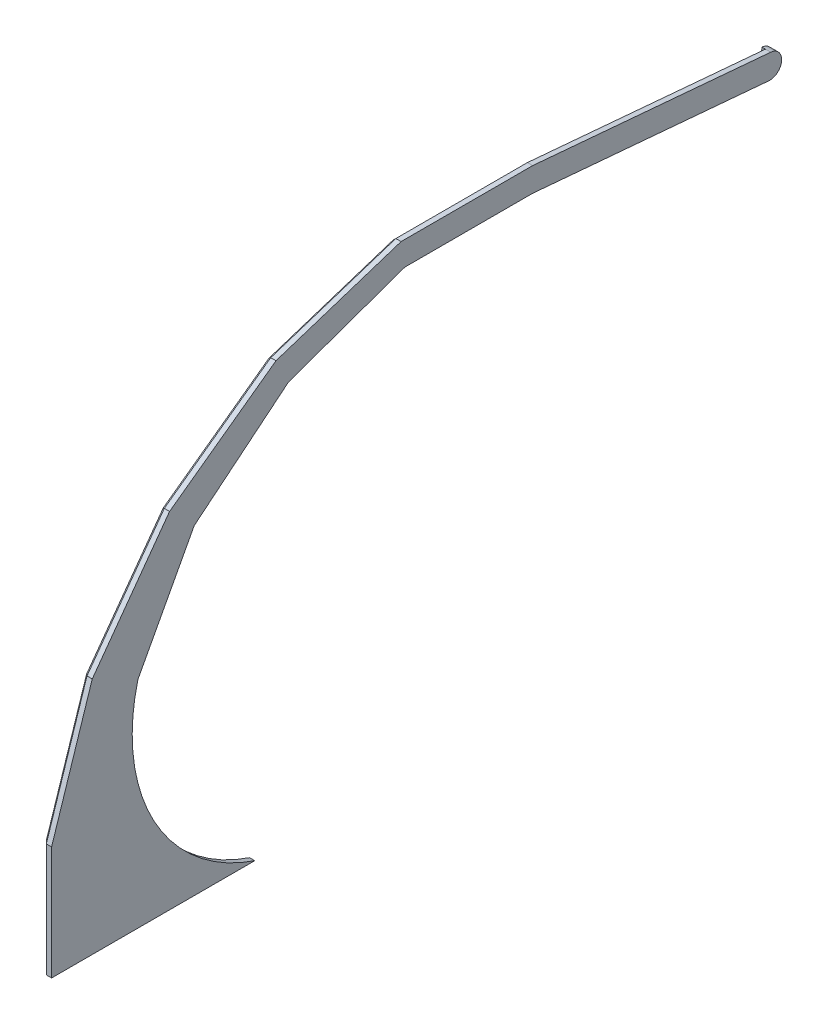
from build123d import *

# Parameters (mm, degrees)
BOSS_EXTRUDE1_DEPTH = 4.4
SKETCH2_W           = 10.6
SKETCH2_H           = 3.6
BOSS_EXTRUDE2_DEPTH = 3


with BuildPart() as part:
    # Sketch1 → Boss-Extrude1 (new body)
    with BuildSketch(Plane(origin=(0, 0, 0), x_dir=(0, 0, -1), z_dir=(1, 0, 0))):
        with BuildLine():
            Line((12.615293263, -92.633282396), (182.615293263, -92.633282396))
            ThreePointArc((182.615293263, -92.633282396), (98.271459614, -21.762843967), (84.825943994, 87.579368501))
            Line((84.825943994, 87.579368501), (131.929787104, 175.483372313))
            Line((131.929787104, 175.483372313), (210.884858569, 240.150484061))
            Line((210.884858569, 240.150484061), (308.236471933, 274.689971372))
            Line((308.236471933, 274.689971372), (415.1194685, 274.721469403))
            Line((415.1194685, 274.721469403), (612.615293263, 257.442823643))
            ThreePointArc((612.615293263, 257.442823643), (623.448797672, 266.533213196), (614.358408118, 277.366717604))
            Line((614.358408118, 277.366717604), (415.1194685, 294.797866154))
            Line((415.1194685, 294.797866154), (305.051694272, 294.797866154))
            Line((305.051694272, 294.797866154), (200.371020359, 260.785053385))
            Line((200.371020359, 260.785053385), (111.324320476, 196.088838941))
            Line((111.324320476, 196.088838941), (46.628106033, 107.042139058))
            Line((46.628106033, 107.042139058), (12.615293263, 2.361465145))
            Line((12.615293263, 2.361465145), (12.615293263, -92.633282396))
        make_face()
    extrude(amount=-BOSS_EXTRUDE1_DEPTH)

    # Sketch2 → Boss-Extrude2 (add)
    with BuildSketch(Plane.ZY.offset(4.4)):
        with BuildLine():
            Line((-614.358408118, 277.366717604), (-614.09694089, 274.37813351))
            Line((-614.09694089, 274.37813351), (-415.1194685, 291.786406641))
            Line((-415.1194685, 291.786406641), (-305.528662602, 291.786406641))
            Line((-305.528662602, 291.786406641), (-201.755236364, 258.068376511))
            Line((-201.755236364, 258.068376511), (-113.48028745, 193.932871967))
            Line((-113.48028745, 193.932871967), (-49.344782906, 105.657923053))
            Line((-49.344782906, 105.657923053), (-15.811778295, 2.453946809))
            Line((-15.811778295, 2.453946809), (-15.811778295, -92.633282396))
            Line((-15.811778295, -92.633282396), (-101.905821199, -92.633282396))
            Line((-101.905821199, -92.633282396), (-66.148126422, 3.910293146))
            Line((-66.148126422, 3.910293146), (-82.152924422, 88.94134))
            Line((-82.152924422, 88.94134), (-129.839029338, 177.574130079))
            Line((-129.839029338, 177.574130079), (-209.517623645, 242.833833686))
            Line((-209.517623645, 242.833833686), (-307.761340769, 277.689831483))
            Line((-307.761340769, 277.689831483), (-415.250010124, 277.721508004))
            Line((-415.250010124, 277.721508004), (-612.876760491, 260.431407737))
            Line((-612.876760491, 260.431407737), (-612.615293263, 257.442823643))
            ThreePointArc((-612.615293263, 257.442823643), (-623.448797672, 266.533213196), (-614.358408118, 277.366717604))
        make_face()
        with Locations((-40.615293263, -60.833282396)):
            Rectangle(SKETCH2_W, SKETCH2_H, mode=Mode.SUBTRACT)
        Polygon((-563.8078494, 273.256849808), (-553.2481856, 274.180700681), (-552.934424927, 270.594399768), (-563.494088726, 269.670548895), align=None, mode=Mode.SUBTRACT)
        Polygon((-473.552609753, 281.153160101), (-462.992945953, 282.077010974), (-462.679185279, 278.490710061), (-473.238849079, 277.566859188), align=None, mode=Mode.SUBTRACT)
        Polygon((-618.923562928, 268.735995644), (-608.363899128, 269.659846517), (-608.050138454, 266.073545604), (-618.609802254, 265.14969473), align=None, mode=Mode.SUBTRACT)
        Polygon((-62.703811589, -4.065338583), (-59.327925332, -5.315695323), (-63.009531289, -15.255804859), (-66.385417546, -14.005448119), align=None, mode=Mode.SUBTRACT)
    extrude(amount=BOSS_EXTRUDE2_DEPTH)


solid = part.part
